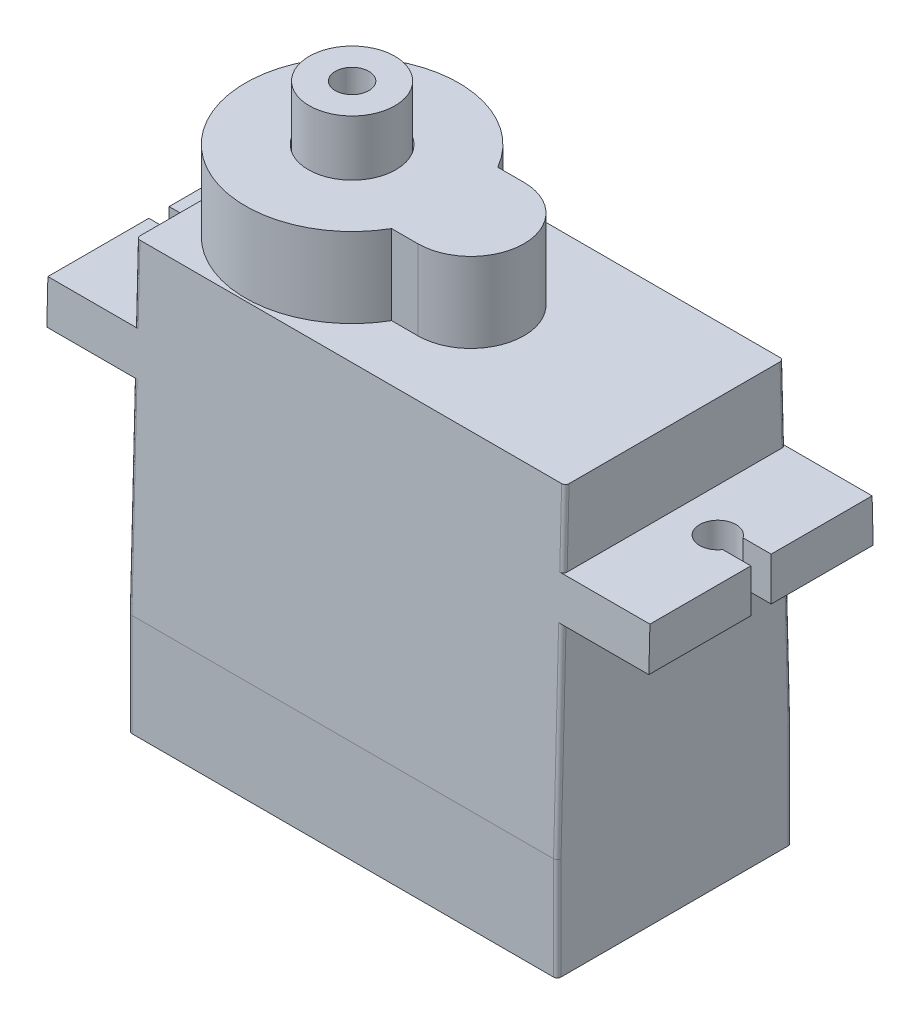
from build123d import *

# Parameters (mm, degrees)
BOSS_EXTRUDE1_DEPTH      = 6.295
BOSS_EXTRUDE2_DEPTH      = 4.28
CUT_EXTRUDE4_DEPTH       = 37.749948639
SKETCH4_R                = 0.975
SKETCH4_W                = 1.511544683
SKETCH4_H                = 1.09
CUT_EXTRUDE1_DEPTH       = 27.991002668
SKETCH5_R                = 1
SKETCH5_R_2              = 0.975
CUT_EXTRUDE2_DEPTH       = 1
FILLET1_R                = 0.3
FILLET3_R                = 0.2
BOSS_EXTRUDE6_DEPTH      = 2.95
BOSS_EXTRUDE6_DEPTH_BACK = 1
SKETCH12_R               = 2.3
SKETCH12_R_2             = 0.9
SKETCH13_R               = 2.35
CUT_EXTRUDE5_DEPTH       = 5


with BuildPart() as part:
    # Sketch1 → Boss-Extrude1 (new, symmetric)
    with BuildSketch(Plane.XY):
        Polygon((-7.13, 6.38), (15.9, 6.38), (15.9, 2.32), (20.54, 2.32), (20.54, 0), (15.9, 0), (15.9, -16.34), (-7.13, -16.34), (-7.13, 0), (-11.77, 0), (-11.77, 2.32), (-7.13, 2.32), align=None)
    extrude(amount=BOSS_EXTRUDE1_DEPTH, both=True)

    # Sketch2 → Boss-Extrude2 (add)
    with BuildSketch(Plane(origin=(0, 6.38, 0), x_dir=(1, 0, 0), z_dir=(0, 1, 0))):
        with BuildLine():
            Line((3.560191336, -2.85), (4.97, -2.85))
            ThreePointArc((4.97, -2.85), (7.82, 0), (4.97, 2.85))
            Line((4.97, 2.85), (3.560191336, 2.85))
            ThreePointArc((3.560191336, 2.85), (-7.13, 0), (3.560191336, -2.85))
        make_face()
    extrude(amount=BOSS_EXTRUDE2_DEPTH)

    # Sketch11 → Cut-Extrude4 (cut, through all)
    with BuildSketch(Plane.ZY.offset(11.77)):
        Polygon((-5.86, 6.38), (-6.295, -10.84), (-6.295, 6.38), align=None)
    cut_extrude4 = extrude(amount=-CUT_EXTRUDE4_DEPTH, mode=Mode.SUBTRACT)

    # Mirror1: Cut-Extrude4 across plane
    add(cut_extrude4.mirror(Plane.XY), mode=Mode.SUBTRACT)

    # Sketch4 → Cut-Extrude1 (cut, through all)
    with BuildSketch(Plane(origin=(0, 0, 0), x_dir=(1, 0, 0), z_dir=(0, 1, 0))):
        with Locations((-9.45, 0)):
            Circle(SKETCH4_R)
        with Locations((-11.014227659, 0)):
            Rectangle(SKETCH4_W, SKETCH4_H)
    cut_extrude1 = extrude(amount=CUT_EXTRUDE1_DEPTH, mode=Mode.SUBTRACT)

    # Mirror2: Cut-Extrude1 across plane
    add(cut_extrude1.mirror(Plane(origin=(4.385, -10.84, 6.295), x_dir=(0, 0, 1), z_dir=(-1, 0, 0))), mode=Mode.SUBTRACT)

    # Sketch5 → Cut-Extrude2 (cut)
    # profile 1 of 4: a face of its own
    with BuildSketch(Plane.XZ.offset(16.34)):
        with Locations((-5.49, 4.35)):
            Circle(SKETCH5_R)
        with Locations((-5.49, 4.35)):
            Circle(SKETCH5_R_2, mode=Mode.SUBTRACT)
    # profile 2 of 4: a face of its own
    with BuildSketch(Plane.XZ.offset(16.34)):
        with Locations((-5.49, -4.35)):
            Circle(SKETCH5_R)
        with Locations((-5.49, -4.35)):
            Circle(SKETCH5_R_2, mode=Mode.SUBTRACT)
    # profile 3 of 4: a face of its own
    with BuildSketch(Plane.XZ.offset(16.34)):
        with Locations((14.26, -4.35)):
            Circle(SKETCH5_R)
        with Locations((14.26, -4.35)):
            Circle(SKETCH5_R_2, mode=Mode.SUBTRACT)
    # profile 4 of 4: a face of its own
    with BuildSketch(Plane.XZ.offset(16.34)):
        with Locations((14.26, 4.35)):
            Circle(SKETCH5_R)
        with Locations((14.26, 4.35)):
            Circle(SKETCH5_R_2, mode=Mode.SUBTRACT)
    extrude(amount=-CUT_EXTRUDE2_DEPTH, mode=Mode.SUBTRACT)

    # Fillet1
    fillet1_edges = [part.edges().sort_by_distance(p)[0] for p in [
        (13.285, -16.34, -4.35),
        (13.285, -16.34, 4.35),
        (-6.465, -16.34, -4.35),
        (-6.465, -16.34, 4.35),
    ]]
    fillet(fillet1_edges, radius=FILLET1_R)

    # Fillet3
    fillet3_edges = [part.edges().sort_by_distance(p)[0] for p in [
        (15.9, -13.59, -6.295),
        (15.9, -13.59, 6.295),
        (-7.13, -13.59, -6.295),
        (-7.13, -13.59, 6.295),
        (-7.13, -5.42, 6.158083624),
        (-7.13, -5.42, -6.158083624),
        (15.9, -5.42, 6.158083624),
        (15.9, -5.42, -6.158083624),
        (15.9, 4.35, -5.911280488),
        (15.9, 4.35, 5.911280488),
        (-7.13, 4.35, -5.911280488),
        (-7.13, 4.35, 5.911280488),
    ]]
    fillet(fillet3_edges, radius=FILLET3_R)

    # Sketch13 → Cut-Extrude5 (cut)
    with BuildSketch(Plane(origin=(0, 13.61, 0), x_dir=(1, 0, 0), z_dir=(0, 1, 0))):
        with Locations((-1.405, 0)):
            Circle(SKETCH13_R)
    extrude(amount=-CUT_EXTRUDE5_DEPTH, mode=Mode.SUBTRACT)


with BuildPart() as body_2:
    # Sketch12 → Boss-Extrude6 (new, two sides: drawn at the far end of the back side and taken through both)
    with BuildSketch(Plane(origin=(0, 10.66, 0), x_dir=(1, 0, 0), z_dir=(0, 1, 0)).offset(-BOSS_EXTRUDE6_DEPTH_BACK)):
        with Locations((-1.405, 0)):
            Circle(SKETCH12_R)
        with Locations((-1.405, 0)):
            Circle(SKETCH12_R_2, mode=Mode.SUBTRACT)
    extrude(amount=BOSS_EXTRUDE6_DEPTH + BOSS_EXTRUDE6_DEPTH_BACK)


solid = Compound([part.part, body_2.part])
